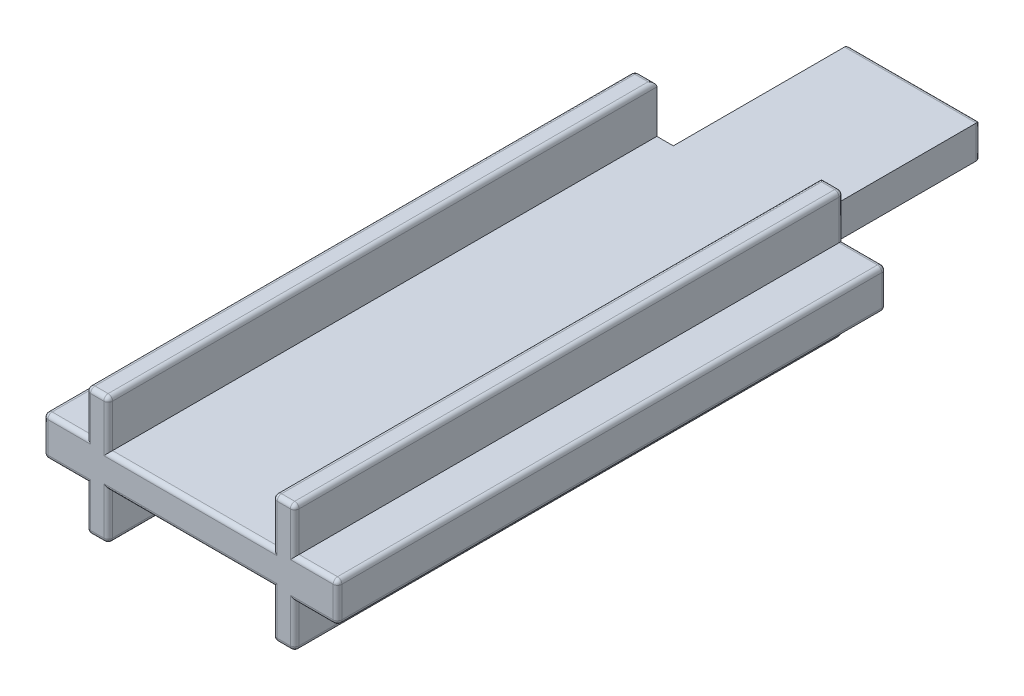
from build123d import *

# Parameters (mm, degrees)
AUFSATZ_LINEAR_AUSTRAGEN1_DEPTH = 25
SKIZZE2_W                       = 6
SKIZZE2_H                       = 1.8
AUFSATZ_LINEAR_AUSTRAGEN2_DEPTH = 8
SKIZZE3_W                       = 7.5
SKIZZE3_H                       = 0.15
SCHNITT_LINEAR_AUSTRAGEN1_DEPTH = 34
VERRUNDUNG1_R                   = 0.2


with BuildPart() as part:
    # Skizze1 → Aufsatz-Linear austragen1 (new body)
    with BuildSketch(Plane.XY):
        Polygon((-4.75, 0.9), (-6.7, 0.9), (-6.7, -0.9), (-4.75, -0.9), (-4.75, -2.9), (-3.75, -2.9), (-3.75, -0.9), (3.75, -0.9), (3.75, -2.9), (4.75, -2.9), (4.75, -0.9), (6.7, -0.9), (6.7, 0.9), (4.75, 0.9), (4.75, 2.9), (3.75, 2.9), (3.75, 0.9), (-3.75, 0.9), (-3.75, 2.9), (-4.75, 2.9), align=None)
    extrude(amount=AUFSATZ_LINEAR_AUSTRAGEN1_DEPTH)

    # Skizze2 → Aufsatz-Linear austragen2 (add)
    with BuildSketch(Plane(origin=(0, 0, 0), x_dir=(-1, 0, 0), z_dir=(0, 0, -1))):
        Rectangle(SKIZZE2_W, SKIZZE2_H)
    extrude(amount=AUFSATZ_LINEAR_AUSTRAGEN2_DEPTH)

    # Skizze3 → Schnitt-Linear austragen1 (cut, through all)
    with BuildSketch(Plane.XY.offset(25)):
        with Locations((0, -0.825)):
            Rectangle(SKIZZE3_W, SKIZZE3_H)
        with Locations((0, 0.825)):
            Rectangle(SKIZZE3_W, SKIZZE3_H)
    extrude(amount=-SCHNITT_LINEAR_AUSTRAGEN1_DEPTH, mode=Mode.SUBTRACT)

    # Verrundung1
    verrundung1_edges = [part.edges().sort_by_distance(p)[0] for p in [
        (0, 0.75, 25),
        (-4.75, -1.9, 25),
        (-4.25, -2.9, 25),
        (-5.725, 0.9, 0),
        (-4.75, 1.9, 0),
        (-4.25, 2.9, 0),
        (-3.75, -1.825, 25),
        (4.25, 2.9, 0),
        (4.75, 1.9, 0),
        (5.725, 0.9, 0),
        (6.7, 0, 0),
        (5.725, -0.9, 0),
        (4.75, -1.9, 0),
        (4.25, -2.9, 0),
        (-4.25, -2.9, 0),
        (-4.75, -1.9, 0),
        (-5.725, -0.9, 0),
        (-6.7, 0, 0),
        (3.75, -1.825, 25),
        (4.25, -2.9, 25),
        (-6.7, 0.9, 12.5),
        (-4.75, 2.9, 12.5),
        (-3.75, 2.9, 12.5),
        (3.75, 2.9, 12.5),
        (4.75, 2.9, 12.5),
        (6.7, 0.9, 12.5),
        (6.7, -0.9, 12.5),
        (4.75, -2.9, 12.5),
        (3.75, -2.9, 12.5),
        (-3.75, -2.9, 12.5),
        (-4.75, -2.9, 12.5),
        (-6.7, -0.9, 12.5),
        (4.75, -1.9, 25),
        (5.725, -0.9, 25),
        (6.7, 0, 25),
        (5.725, 0.9, 25),
        (-6.7, 0, 25),
        (4.75, 1.9, 25),
        (4.25, 2.9, 25),
        (3.75, 1.825, 25),
        (-3.75, 1.825, 25),
        (3, 0, -8),
        (-3, 0, -8),
        (-4.25, 2.9, 25),
        (0, 0.75, -8),
        (0, -0.75, -8),
        (-4.75, 1.9, 25),
        (-5.725, 0.9, 25),
        (0, -0.75, 25),
        (-5.725, -0.9, 25),
    ]]
    fillet(verrundung1_edges, radius=VERRUNDUNG1_R)


solid = part.part
